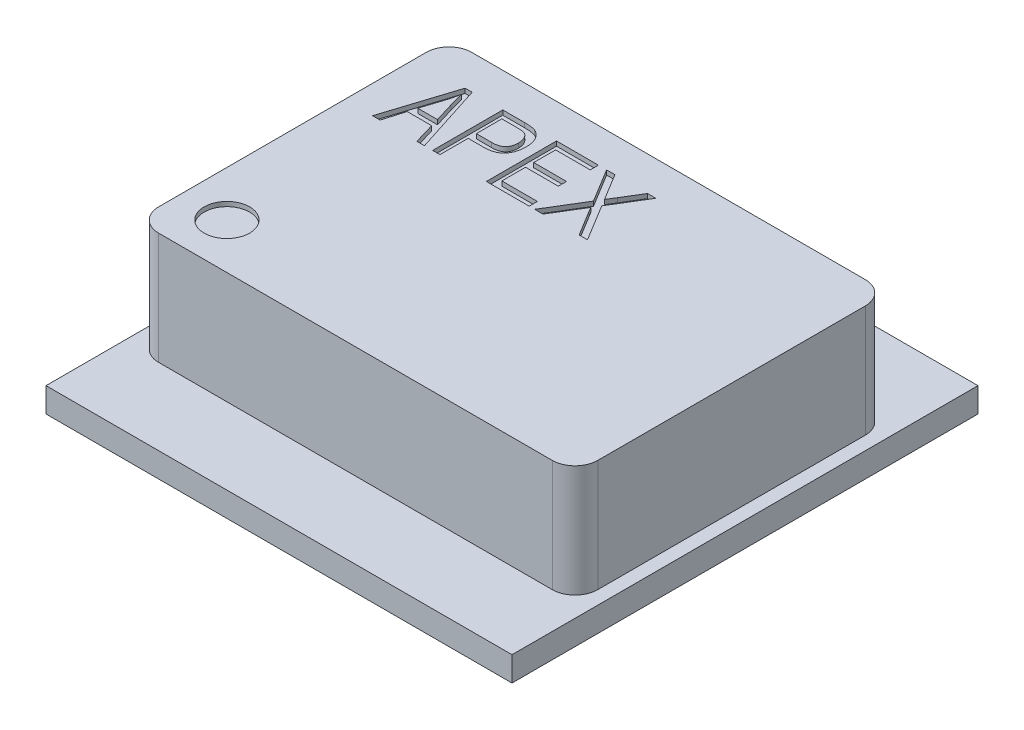
from build123d import *

# Parameters (mm, degrees)
SKETCH1_W           = 10.24
SKETCH1_H           = 10.24
BOSS_EXTRUDE1_DEPTH = 0.54
SKETCH2_W           = 9.65
SKETCH2_H           = 6.88
BOSS_EXTRUDE2_DEPTH = 2.46
FILLET1_R           = 0.5
SKETCH3_R           = 0.5
CUT_EXTRUDE1_DEPTH  = 0.1
CUT_EXTRUDE2_DEPTH  = 0.1


with BuildPart() as part:
    # Sketch1 → Boss-Extrude1 (new body)
    with BuildSketch(Plane(origin=(0, 0, 0), x_dir=(1, 0, 0), z_dir=(0, 1, 0))):
        Rectangle(SKETCH1_W, SKETCH1_H)
    extrude(amount=BOSS_EXTRUDE1_DEPTH)

    # Sketch2 → Boss-Extrude2 (add)
    with BuildSketch(Plane(origin=(0, 0.54, 0), x_dir=(1, 0, 0), z_dir=(0, 1, 0))):
        Rectangle(SKETCH2_W, SKETCH2_H)
    extrude(amount=BOSS_EXTRUDE2_DEPTH)

    # Fillet1
    fillet1_edges = [part.edges().sort_by_distance(p)[0] for p in [
        (4.825, 1.77, 3.44),
        (4.825, 1.77, -3.44),
        (-4.825, 1.77, -3.44),
        (-4.825, 1.77, 3.44),
    ]]
    fillet(fillet1_edges, radius=FILLET1_R)

    # Sketch3 → Cut-Extrude1 (cut)
    with BuildSketch(Plane(origin=(0, 3, 0), x_dir=(1, 0, 0), z_dir=(0, 1, 0))):
        with Locations((-3.825, -2.44)):
            Circle(SKETCH3_R)
    extrude(amount=-CUT_EXTRUDE1_DEPTH, mode=Mode.SUBTRACT)

    # Sketch4 → Cut-Extrude2 (cut)
    with BuildSketch(Plane(origin=(0, 3, 0), x_dir=(1, 0, 0), z_dir=(0, 1, 0))):
        Polygon((-4.208905933, 1.144195858), (-3.716714341, 2.685187069), (-3.560676473, 2.685187069), (-3.06817218, 1.144195858), (-3.234529186, 1.144195858), (-3.369303376, 1.604491934), (-3.907774737, 1.604491934), (-4.042236227, 1.144195858), align=None)
        with BuildLine():
            Line((-3.855240946, 1.78460779), (-3.422149869, 1.78460779))
            Line((-3.422149869, 1.78460779), (-3.550982738, 2.208005131))
            add(Edge.make_bspline(
                [(-3.550982738, 2.208005131), (-3.555802408, 2.22384126), (-3.565212111, 2.254758994), (-3.578537108, 2.300032071), (-3.591326078, 2.342972738), (-3.602250322, 2.38388053), (-3.61311318, 2.422223196), (-3.622481656, 2.458427427), (-3.630891424, 2.492313544), (-3.636057432, 2.514238953), (-3.638539057, 2.524771385)],
                knots=[0, 0, 0, 0, 4.9659e-05, 9.6953e-05, 0.000141582, 0.000184064, 0.000223969, 0.000261133, 0.000296247, 0.00032871, 0.00032871, 0.00032871, 0.00032871], degree=3))
            add(Edge.make_bspline(
                [(-3.638539057, 2.524771385), (-3.643044276, 2.500238484), (-3.65204873, 2.451205272), (-3.668927225, 2.378161214), (-3.687705063, 2.305248967), (-3.702651529, 2.257146174), (-3.710147617, 2.233021222)],
                knots=[0, 0, 0, 0, 7.482e-05, 0.00014954, 0.000224855, 0.000300632, 0.000300632, 0.000300632, 0.000300632], degree=3))
            Line((-3.710147617, 2.233021222), (-3.855240946, 1.78460779))
        make_face(mode=Mode.SUBTRACT)
        with BuildLine():
            Line((-2.888056324, 1.144195858), (-2.888056324, 2.685187069))
            Line((-2.888056324, 2.685187069), (-2.413375996, 2.685187069))
            add(Edge.make_bspline(
                [(-2.413375996, 2.685187069), (-2.399822743, 2.685199787), (-2.373748311, 2.685224254), (-2.336020957, 2.683378466), (-2.30094543, 2.681513344), (-2.268644767, 2.677914478), (-2.239094529, 2.673984648), (-2.212324896, 2.66907385), (-2.188330523, 2.662867435), (-2.173405243, 2.657853313), (-2.166342096, 2.655480461)],
                knots=[0, 0, 0, 0, 4.0652e-05, 7.8209e-05, 0.0001133, 0.000146002, 0.000175676, 0.000202722, 0.000227599, 0.000249948, 0.000249948, 0.000249948, 0.000249948], degree=3))
            add(Edge.make_bspline(
                [(-2.166342096, 2.655480461), (-2.15739835, 2.652018743), (-2.139532052, 2.645103513), (-2.114366349, 2.631451435), (-2.09035999, 2.616070999), (-2.067785044, 2.598561502), (-2.046773915, 2.578653074), (-2.026997713, 2.556783142), (-2.008849339, 2.532502116), (-1.992128119, 2.506327155), (-1.976558078, 2.478522333), (-1.963702465, 2.448747644), (-1.952154302, 2.417630839), (-1.943367912, 2.384807465), (-1.935942576, 2.3505097), (-1.931213224, 2.314633597), (-1.927842425, 2.277176403), (-1.92757514, 2.251687241), (-1.927438426, 2.238649843)],
                knots=[0, 0, 0, 0, 2.8745e-05, 5.7421e-05, 8.5698e-05, 0.000114221, 0.000142979, 0.000172428, 0.000202572, 0.000233798, 0.000265568, 0.000298048, 0.000330989, 0.000365052, 0.000399887, 0.000436194, 0.000473536, 0.000512635, 0.000512635, 0.000512635, 0.000512635], degree=3))
            add(Edge.make_bspline(
                [(-1.927438426, 2.238649843), (-1.927703132, 2.221543206), (-1.928220835, 2.188086636), (-1.93330388, 2.139152317), (-1.941751736, 2.092755631), (-1.953277936, 2.048673687), (-1.968247434, 2.006973056), (-1.986783863, 1.967763319), (-2.008529273, 1.930904056), (-2.033354788, 1.89632649), (-2.062609276, 1.864852564), (-2.097135287, 1.83792685), (-2.136198408, 1.814898294), (-2.180286283, 1.796594194), (-2.228949187, 1.781809429), (-2.282628295, 1.771730453), (-2.3411162, 1.765892858), (-2.381674975, 1.765038653), (-2.402744157, 1.764594917)],
                knots=[0, 0, 0, 0, 5.1307e-05, 0.000100344, 0.000147388, 0.000192669, 0.000236884, 0.000280107, 0.000322581, 0.000365113, 0.000407588, 0.000451004, 0.000495999, 0.000543218, 0.000593866, 0.000648324, 0.000706789, 0.000769993, 0.000769993, 0.000769993, 0.000769993], degree=3))
            Line((-2.402744157, 1.764594917), (-2.727953341, 1.764594917))
            Line((-2.727953341, 1.764594917), (-2.727953341, 1.144195858))
            Line((-2.727953341, 1.144195858), (-2.888056324, 1.144195858))
        make_face()
        with BuildLine():
            Line((-2.727953341, 1.944710773), (-2.392737721, 1.944710773))
            add(Edge.make_bspline(
                [(-2.392737721, 1.944710773), (-2.380016461, 1.944996579), (-2.355368886, 1.945550331), (-2.319593959, 1.948503929), (-2.28645598, 1.954137106), (-2.255965679, 1.961851391), (-2.228207938, 1.971910844), (-2.203044284, 1.984006949), (-2.180618389, 1.998565987), (-2.160576979, 2.015206906), (-2.143495605, 2.034541806), (-2.128130148, 2.05560326), (-2.115669137, 2.079385756), (-2.105485872, 2.105324963), (-2.097214244, 2.133336313), (-2.091756565, 2.163637248), (-2.08826807, 2.196145263), (-2.087788442, 2.21862743), (-2.087541409, 2.230206912)],
                knots=[0, 0, 0, 0, 3.817e-05, 7.3955e-05, 0.000107576, 0.000138899, 0.000168179, 0.00019601, 0.000222464, 0.000248208, 0.000273892, 0.000299664, 0.000326244, 0.000354174, 0.000383168, 0.000413711, 0.000446413, 0.000481145, 0.000481145, 0.000481145, 0.000481145], degree=3))
            add(Edge.make_bspline(
                [(-2.087541409, 2.230206912), (-2.08789706, 2.245247803), (-2.088585266, 2.274352792), (-2.095703866, 2.316217414), (-2.106715605, 2.354836551), (-2.122831996, 2.389433378), (-2.141679929, 2.419771411), (-2.162318289, 2.445723404), (-2.185368747, 2.466112503), (-2.206821105, 2.478820504), (-2.225660971, 2.486835174), (-2.242449858, 2.491781091), (-2.261836205, 2.495665981), (-2.283750042, 2.499067941), (-2.30814868, 2.501936461), (-2.335078678, 2.50362652), (-2.364580349, 2.505013397), (-2.385126647, 2.505051368), (-2.395864732, 2.505071213)],
                knots=[0, 0, 0, 0, 4.5082e-05, 8.7237e-05, 0.000127012, 0.000165211, 0.000201307, 0.000233979, 0.000264337, 0.000293082, 0.000308356, 0.000325668, 0.000345477, 0.000367635, 0.000392187, 0.000419145, 0.000448566, 0.000480775, 0.000480775, 0.000480775, 0.000480775], degree=3))
            Line((-2.395864732, 2.505071213), (-2.727953341, 2.505071213))
            Line((-2.727953341, 2.505071213), (-2.727953341, 1.944710773))
        make_face(mode=Mode.SUBTRACT)
        Polygon((-1.707296825, 1.144195858), (-1.707296825, 2.685187069), (-0.786704673, 2.685187069), (-0.786704673, 2.505071213), (-1.547193842, 2.505071213), (-1.547193842, 2.024762264), (-0.826730419, 2.024762264), (-0.826730419, 1.844646408), (-1.547193842, 1.844646408), (-1.547193842, 1.324311714), (-0.7666918, 1.324311714), (-0.7666918, 1.144195858), align=None)
        with BuildLine():
            Line((-0.646614563, 1.144195858), (-0.157549982, 1.947837784))
            Line((-0.157549982, 1.947837784), (-0.606588817, 2.685187069))
            Line((-0.606588817, 2.685187069), (-0.423658651, 2.685187069))
            Line((-0.423658651, 2.685187069), (-0.181315269, 2.28743122))
            add(Edge.make_bspline(
                [(-0.181315269, 2.28743122), (-0.169736699, 2.268361701), (-0.148036169, 2.232621651), (-0.117649456, 2.182287392), (-0.091062059, 2.139057874), (-0.074879604, 2.112326527), (-0.067492054, 2.100123238)],
                knots=[0, 0, 0, 0, 6.6928e-05, 0.000125437, 0.000176385, 0.000219181, 0.000219181, 0.000219181, 0.000219181], degree=3))
            add(Edge.make_bspline(
                [(-0.067492054, 2.100123238), (-0.049678986, 2.127999568), (-0.012690335, 2.185884479), (0.02309097, 2.244523598), (0.041640643, 2.274923175)],
                knots=[0, 0, 0, 0, 9.9242e-05, 0.000206075, 0.000206075, 0.000206075, 0.000206075], degree=3))
            Line((0.041640643, 2.274923175), (0.291176152, 2.685187069))
            Line((0.291176152, 2.685187069), (0.474106318, 2.685187069))
            Line((0.474106318, 2.685187069), (0.025067483, 1.947212382))
            Line((0.025067483, 1.947212382), (0.514132064, 1.144195858))
            Line((0.514132064, 1.144195858), (0.331201898, 1.144195858))
            Line((0.331201898, 1.144195858), (-0.009642343, 1.703618195))
            add(Edge.make_bspline(
                [(-0.009642343, 1.703618195), (-0.01890825, 1.719051357), (-0.037706972, 1.750362242), (-0.056640217, 1.781591969), (-0.06624125, 1.797428536)],
                knots=[0, 0, 0, 0, 5.4003e-05, 0.000109562, 0.000109562, 0.000109562, 0.000109562], degree=3))
            add(Edge.make_bspline(
                [(-0.06624125, 1.797428536), (-0.074099113, 1.784632259), (-0.088514391, 1.761157446), (-0.107567841, 1.72889146), (-0.123536239, 1.703682546), (-0.132254181, 1.688732713), (-0.135973603, 1.682354517)],
                knots=[0, 0, 0, 0, 4.5049e-05, 8.2642e-05, 0.000112407, 0.000134556, 0.000134556, 0.000134556, 0.000134556], degree=3))
            Line((-0.135973603, 1.682354517), (-0.463684397, 1.144195858))
            Line((-0.463684397, 1.144195858), (-0.646614563, 1.144195858))
        make_face()
    extrude(amount=-CUT_EXTRUDE2_DEPTH, mode=Mode.SUBTRACT)


solid = part.part
